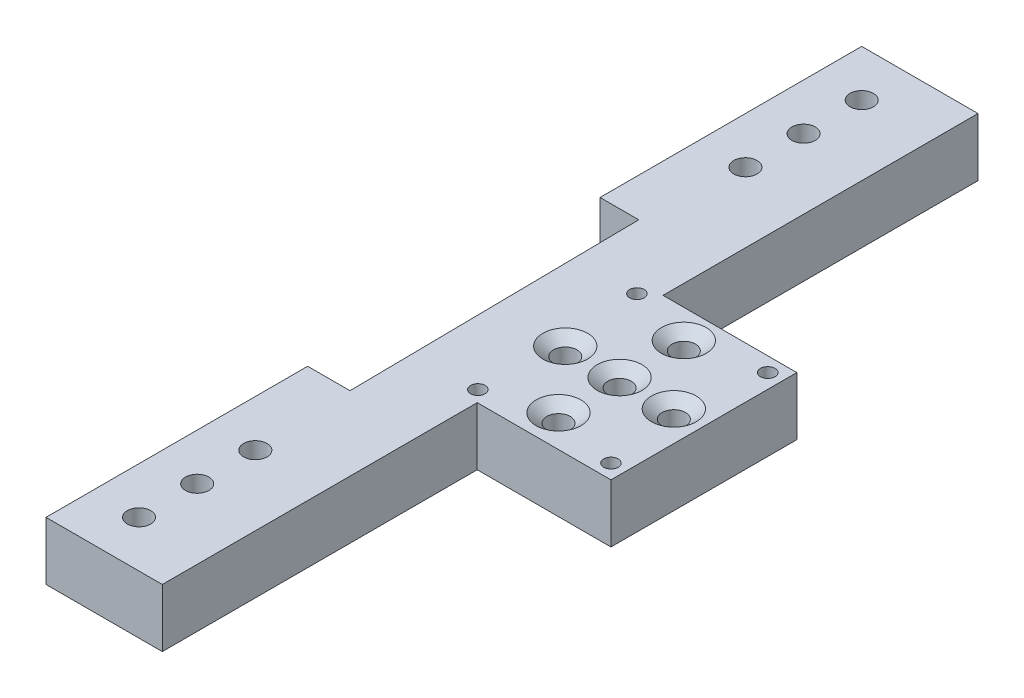
from build123d import *

# Parameters (mm, degrees)
BOSS_EXTRUDE1_DEPTH                                = 12.7
F_1_4_20_TAPPED_HOLE1_D                            = 5.1054
F_1_4_20_TAPPED_HOLE1_DEPTH                        = 12.7
F_1_4_20_TAPPED_HOLE2_D                            = 5.1054
F_1_4_20_TAPPED_HOLE2_DEPTH                        = 12.7
LPATTERN1_COUNT                                    = 3
LPATTERN1_PITCH                                    = 12.7
LPATTERN2_COUNT                                    = 3
LPATTERN2_PITCH                                    = 12.7
CSK_FOR_10_FLAT_HEAD_MACHINE_SCREW_100_D           = 5.1054
CSK_FOR_10_FLAT_HEAD_MACHINE_SCREW_100_DEPTH       = 12.7
CSK_FOR_10_FLAT_HEAD_MACHINE_SCREW_100_CSINK_D     = 9.779
CSK_FOR_10_FLAT_HEAD_MACHINE_SCREW_100_CSINK_ANGLE = 100
F_1_8_0_125_DIAMETER_HOLE1_D                       = 3.175
F_1_8_0_125_DIAMETER_HOLE1_DEPTH                   = 12.7
CSK_FOR_10_FLAT_HEAD_MACHINE_SCREW_2_D             = 5.1054
CSK_FOR_10_FLAT_HEAD_MACHINE_SCREW_2_DEPTH         = 12.7
CSK_FOR_10_FLAT_HEAD_MACHINE_SCREW_2_CSINK_D       = 9.779
CSK_FOR_10_FLAT_HEAD_MACHINE_SCREW_2_CSINK_ANGLE   = 100


with BuildPart() as part:
    # Sketch1 → Boss-Extrude1 (new body)
    with BuildSketch(Plane(origin=(0, 0, 0), x_dir=(1, 0, 0), z_dir=(0, 1, 0))):
        Polygon((24.616308072, 0), (53.826308072, 0), (53.826308072, 40.5892), (24.616308072, 40.5892), (24.616308072, 109.3724), (-0.783691928, 109.3724), (-0.783691928, 52.2224), (7.674508072, 52.2224), (8.4582, -11.6332), (-0.783691928, -11.6332), (-0.783691928, -68.7832), (24.616308072, -68.7832), align=None)
    extrude(amount=BOSS_EXTRUDE1_DEPTH)

    # 1/4-20 Tapped Hole1
    with Locations(Plane(origin=(0, 12.7, 0), x_dir=(1, 0, 0), z_dir=(0, 1, 0))):
        with Locations((9.376308072, 99.2124)):
            f_1_4_20_tapped_hole1 = Hole(F_1_4_20_TAPPED_HOLE1_D / 2, depth=F_1_4_20_TAPPED_HOLE1_DEPTH)

    # 1/4-20 Tapped Hole2
    with Locations(Plane(origin=(0, 12.7, 0), x_dir=(1, 0, 0), z_dir=(0, 1, 0))):
        with Locations((9.376308072, -58.6232)):
            f_1_4_20_tapped_hole2 = Hole(F_1_4_20_TAPPED_HOLE2_D / 2, depth=F_1_4_20_TAPPED_HOLE2_DEPTH)

    # LPattern1: 1/4-20 Tapped Hole1 ×3
    with Locations(*[(0, 0, i * LPATTERN1_PITCH) for i in range(1, LPATTERN1_COUNT)]):
        add(f_1_4_20_tapped_hole1, mode=Mode.SUBTRACT)

    # LPattern2: 1/4-20 Tapped Hole2 ×3
    with Locations(*[(0, 0, -i * LPATTERN2_PITCH) for i in range(1, LPATTERN2_COUNT)]):
        add(f_1_4_20_tapped_hole2, mode=Mode.SUBTRACT)

    # CSK for _10 Flat Head Machine Screw _100
    with Locations(Plane(origin=(0, 12.7, 0), x_dir=(1, 0, 0), z_dir=(0, 1, 0))):
        with Locations((35.411308072, 20.2946), (35.411308072, 34.326173542), (35.411308072, 6.960743489)):
            CounterSinkHole(CSK_FOR_10_FLAT_HEAD_MACHINE_SCREW_100_D / 2, CSK_FOR_10_FLAT_HEAD_MACHINE_SCREW_100_CSINK_D / 2, depth=CSK_FOR_10_FLAT_HEAD_MACHINE_SCREW_100_DEPTH, counter_sink_angle=CSK_FOR_10_FLAT_HEAD_MACHINE_SCREW_100_CSINK_ANGLE)

    # 1/8 (0.125) Diameter Hole1
    with Locations(Plane(origin=(0, 12.7, 0), x_dir=(1, 0, 0), z_dir=(0, 1, 0))):
        with Locations((21.441308072, 38.0492), (22.214178029, 2.54), (50.651308072, 3.175), (50.651308072, 37.4142)):
            Hole(F_1_8_0_125_DIAMETER_HOLE1_D / 2, depth=F_1_8_0_125_DIAMETER_HOLE1_DEPTH)

    # CSK for _10 Flat Head Machine Screw  2
    with Locations(Plane(origin=(0, 12.7, 0), x_dir=(1, 0, 0), z_dir=(0, 1, 0))):
        with Locations((47.260541085, 20.2946), (23.544844519, 20.2946)):
            CounterSinkHole(CSK_FOR_10_FLAT_HEAD_MACHINE_SCREW_2_D / 2, CSK_FOR_10_FLAT_HEAD_MACHINE_SCREW_2_CSINK_D / 2, depth=CSK_FOR_10_FLAT_HEAD_MACHINE_SCREW_2_DEPTH, counter_sink_angle=CSK_FOR_10_FLAT_HEAD_MACHINE_SCREW_2_CSINK_ANGLE)


solid = part.part
